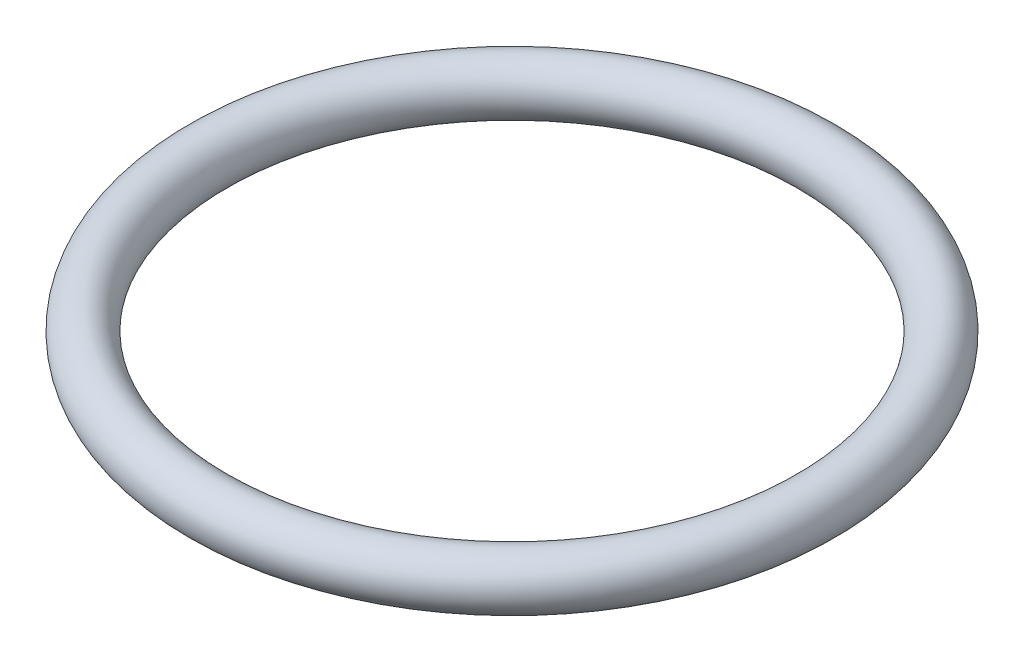
from build123d import *

# Parameters (mm, degrees)
ESQUISSE1_R = 2.5


with BuildPart() as part:
    # Esquisse1 → Révolution1 (revolve)
    with BuildSketch(Plane.XY):
        with Locations((29, 0)):
            Circle(ESQUISSE1_R)
    revolve(axis=Axis((0, 0, 0), (0, 1, 0)))


solid = part.part
